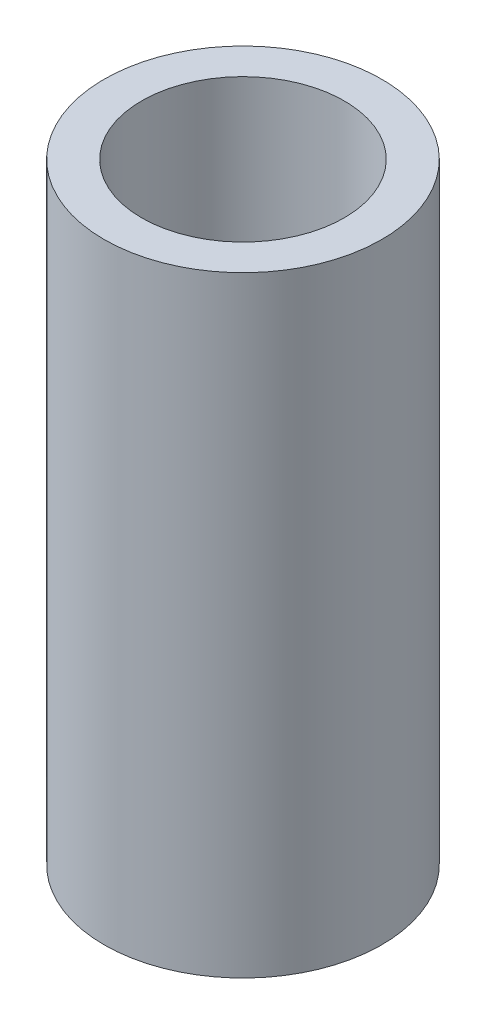
from build123d import *

# Parameters (mm, degrees)
SKETCH_1_R      = 5
SKETCH_1_R_2    = 3.65
EXTRUDE_1_DEPTH = 22


with BuildPart() as part:
    # Эскиз1 → Бобышка-Вытянуть1 (new body)
    with BuildSketch(Plane(origin=(0, 0, 0), x_dir=(1, 0, 0), z_dir=(0, 1, 0))):
        Circle(SKETCH_1_R)
        Circle(SKETCH_1_R_2, mode=Mode.SUBTRACT)
    extrude(amount=EXTRUDE_1_DEPTH)


solid = part.part
